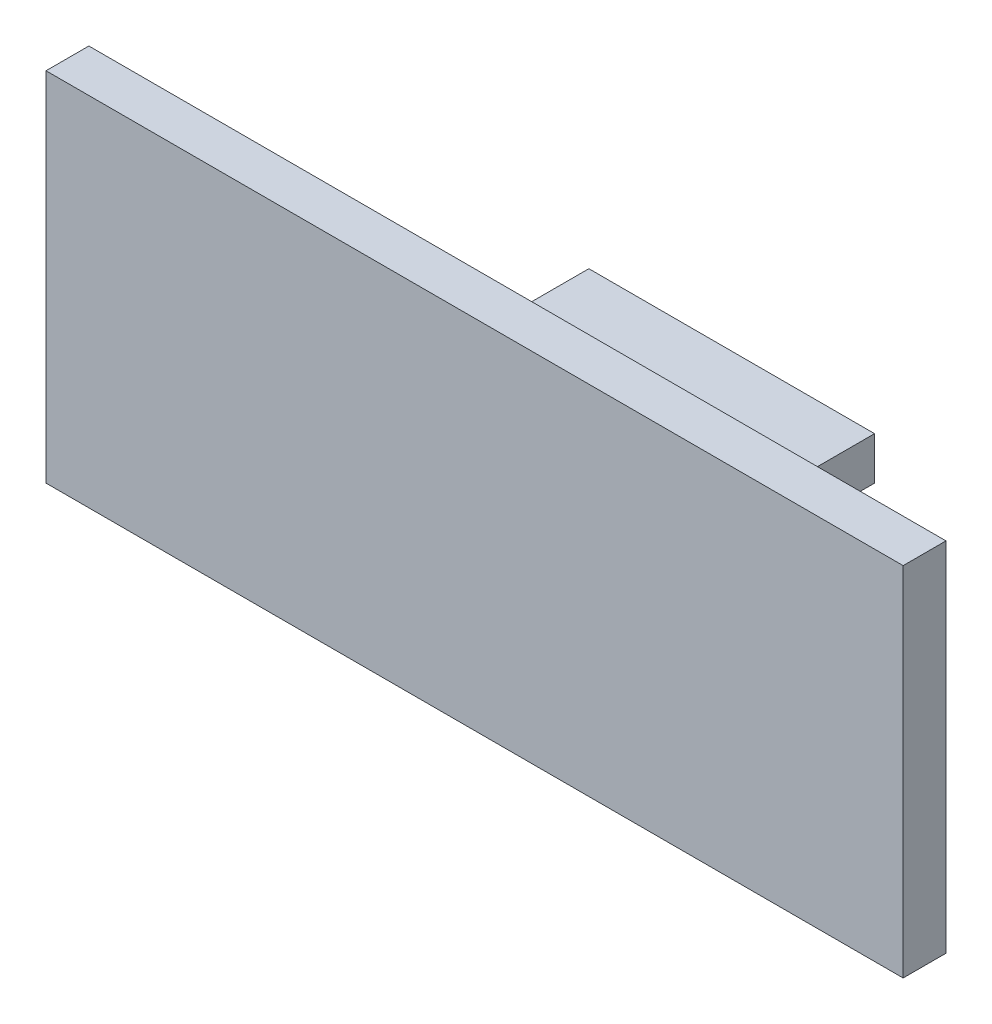
from build123d import *

# Parameters (mm, degrees)
CROQUIS1_W              = 60
CROQUIS1_H              = 25
SALIENTE_EXTRUIR1_DEPTH = 5
CROQUIS2_W              = 20
CROQUIS2_H              = 3
SALIENTE_EXTRUIR2_DEPTH = 10
CROQUIS3_W              = 60
CROQUIS3_H              = 25
CORTAR_EXTRUIR1_DEPTH   = 2
CROQUIS4_W              = 20
CROQUIS4_H              = 3
SALIENTE_EXTRUIR3_DEPTH = 5


with BuildPart() as part:
    # Croquis1 → Saliente-Extruir1 (new body)
    with BuildSketch(Plane.XY):
        Rectangle(CROQUIS1_W, CROQUIS1_H)
    extrude(amount=SALIENTE_EXTRUIR1_DEPTH)

    # Croquis2 → Saliente-Extruir2 (add)
    with BuildSketch(Plane(origin=(0, 0, 0), x_dir=(-1, 0, 0), z_dir=(0, 0, -1))):
        Rectangle(CROQUIS2_W, CROQUIS2_H)
    extrude(amount=SALIENTE_EXTRUIR2_DEPTH)

    # Croquis3 → Cortar-Extruir1 (cut)
    with BuildSketch(Plane.XY.offset(5)):
        Rectangle(CROQUIS3_W, CROQUIS3_H)
    extrude(amount=-CORTAR_EXTRUIR1_DEPTH, mode=Mode.SUBTRACT)

    # Croquis4 → Saliente-Extruir3 (add)
    with BuildSketch(Plane(origin=(0, 0, -10), x_dir=(-1, 0, 0), z_dir=(0, 0, -1))):
        Rectangle(CROQUIS4_W, CROQUIS4_H)
    extrude(amount=SALIENTE_EXTRUIR3_DEPTH)


solid = part.part
